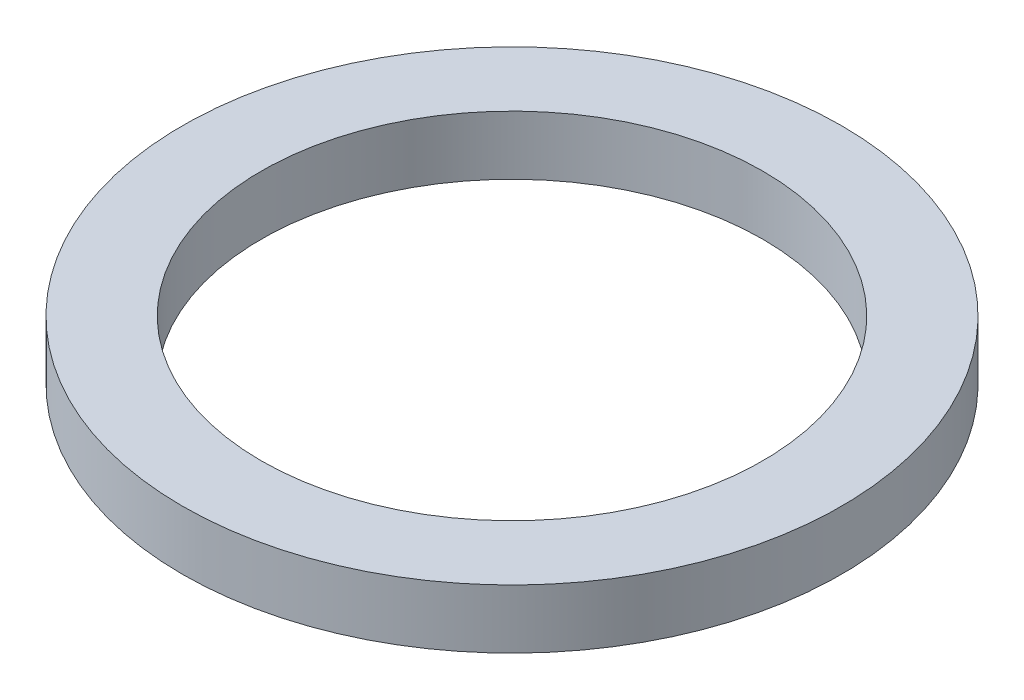
from build123d import *

# Parameters (mm, degrees)
SKETCH2_R           = 4.2545
SKETCH2_R_2         = 3.2385
BOSS_EXTRUDE1_DEPTH = 0.762


with BuildPart() as part:
    # Sketch2 → Boss-Extrude1 (new body)
    with BuildSketch(Plane(origin=(0, 0, 0), x_dir=(1, 0, 0), z_dir=(0, 1, 0))):
        Circle(SKETCH2_R)
        Circle(SKETCH2_R_2, mode=Mode.SUBTRACT)
    extrude(amount=BOSS_EXTRUDE1_DEPTH)


solid = part.part
